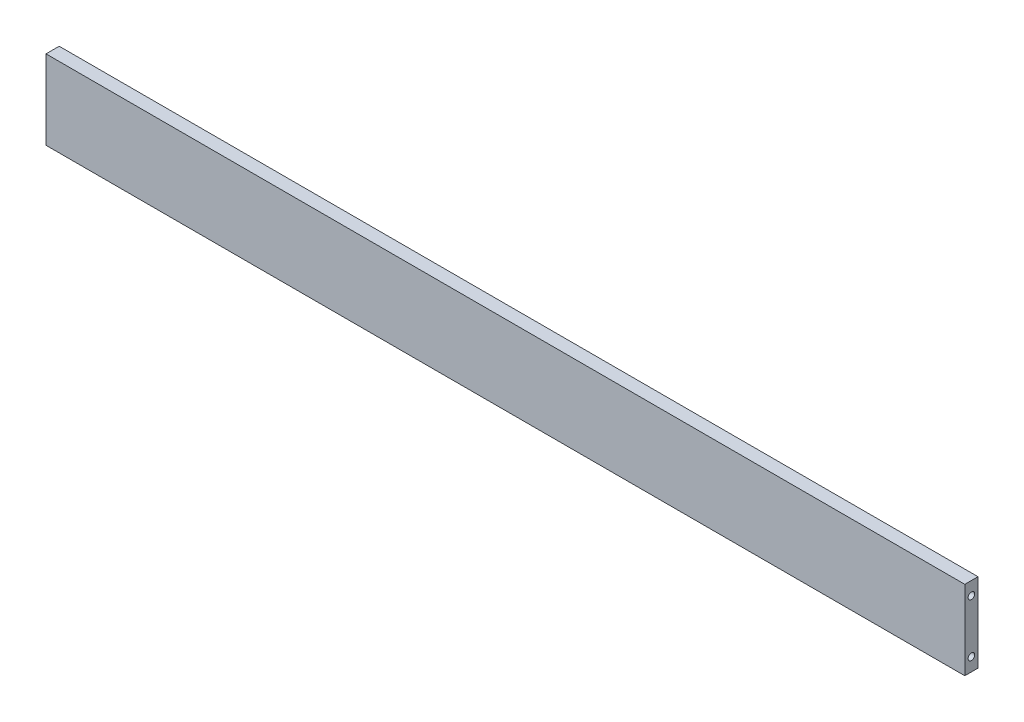
from build123d import *

# Parameters (mm, degrees)
SKETCH_1_W             = 696
SKETCH_1_H             = 60
EXTRUDE_1_DEPTH        = 5
PATTERN_LINEAR_1_COUNT = 2
PATTERN_LINEAR_1_PITCH = 40
HOLE_WIZARD_M6_1_D     = 5
HOLE_WIZARD_M6_1_DEPTH = 15
HOLE_WIZARD_M6_1_TIP   = 1.502151548


with BuildPart() as part:
    # 草图1 → 凸台-拉伸1 (new body, symmetric)
    with BuildSketch(Plane.XY):
        Rectangle(SKETCH_1_W, SKETCH_1_H)
    extrude(amount=EXTRUDE_1_DEPTH, both=True)

    # 草图11 → M6 螺纹孔2 (revolve, cut)
    with BuildSketch(Plane(origin=(348, 20, 0), x_dir=(0, 0, -1), z_dir=(0, 1, 0))):
        Polygon((0, 0), (0, 16.502151548), (2.5, 15), (2.5, 0), align=None)
    hole_wizard_m6_2 = revolve(axis=Axis((354.35, 20, 0), (-1, 0, 0)), mode=Mode.SUBTRACT)

    # 阵列(线性)1: M6 螺纹孔2 ×2
    with Locations(*[(0, -i * PATTERN_LINEAR_1_PITCH, 0) for i in range(1, PATTERN_LINEAR_1_COUNT)]):
        add(hole_wizard_m6_2, mode=Mode.SUBTRACT)

    # 镜向2: M6 螺纹孔2 across plane
    add(hole_wizard_m6_2.mirror(Plane(origin=(0, 0, 0), x_dir=(0, 0, 1), z_dir=(1, 0, 0))), mode=Mode.SUBTRACT)

    # 镜向2 copy 1 sketch → 镜向2 copy 1 (revolve, cut)
    with BuildSketch(Plane(origin=(-348, -20, 0), x_dir=(0, 0, -1), z_dir=(0, 1, 0))):
        Polygon((0, 0), (0, -16.502151548), (2.5, -15), (2.5, 0), align=None)
    revolve(axis=Axis((-354.35, -20, 0), (-1, 0, 0)), mode=Mode.SUBTRACT)

    # M6 螺纹孔1
    with Locations(Plane(origin=(-300, -30, 0), x_dir=(0, 0, -1), z_dir=(0, -1, 0))):
        with Locations((0, 0), (0, 150), (0, 450), (0, 600), (0, 300)):
            Hole(HOLE_WIZARD_M6_1_D / 2, depth=HOLE_WIZARD_M6_1_DEPTH)
            with Locations((0, 0, -(HOLE_WIZARD_M6_1_DEPTH + HOLE_WIZARD_M6_1_TIP / 2))):  # 118° drill point
                Cone(0, HOLE_WIZARD_M6_1_D / 2, HOLE_WIZARD_M6_1_TIP, mode=Mode.SUBTRACT)


solid = part.part
